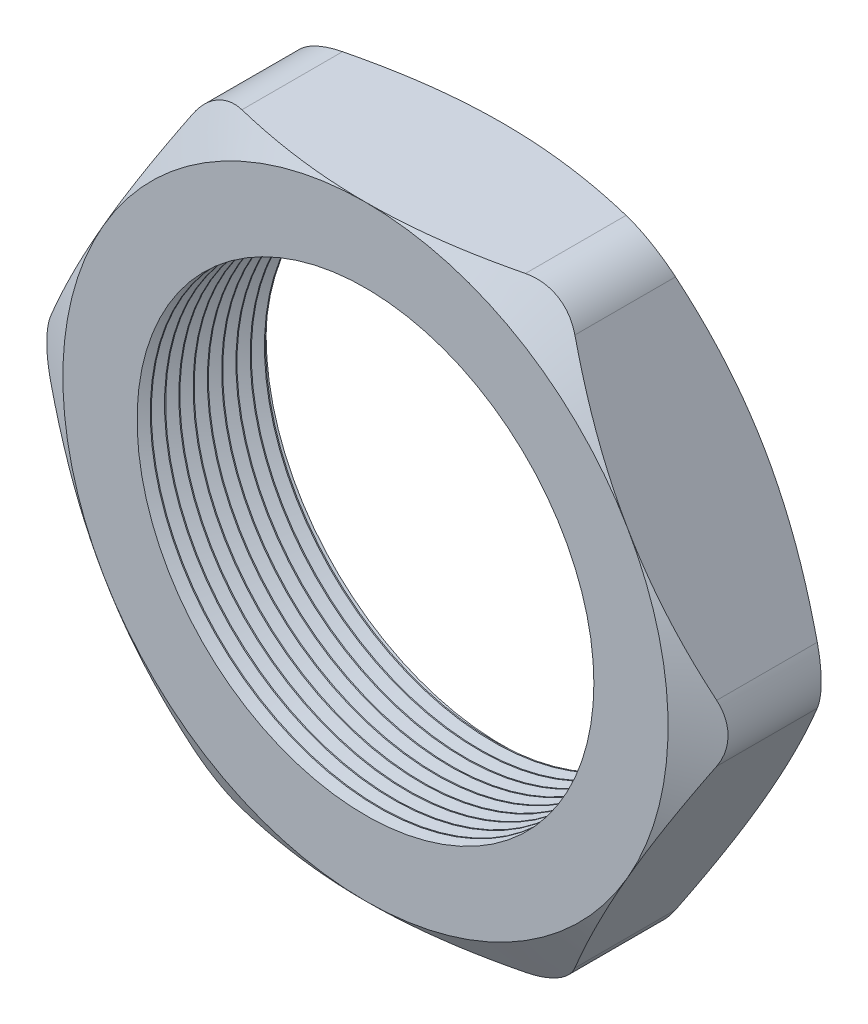
from build123d import *

# Parameters (mm, degrees)
SKETCH1_R          = 10.16
EXTRUDE1_DEPTH     = 6.096
SKETCH2_OUTSIDE_W  = 65.986
SKETCH2_OUTSIDE_H  = 61.82
SKETCH2_OUTSIDE_R  = 13.462
CUT_EXTRUDE1_DEPTH = 7.096
CUT_EXTRUDE1_DRAFT = -60
SKETCH3_OUTSIDE_W  = 65.986
SKETCH3_OUTSIDE_H  = 61.82
SKETCH3_OUTSIDE_R  = 13.462
CUT_EXTRUDE2_DEPTH = 7.096
CUT_EXTRUDE2_DRAFT = -60
FILLET1_R          = 2.54
LPATTERN1_COUNT    = 10
LPATTERN1_PITCH    = 0.635


with BuildPart() as part:
    # Sketch1 → Extrude1 (new body)
    with BuildSketch(Plane.XY):
        Polygon((-15.544578648, 0), (-7.772289324, -13.462), (7.772289324, -13.462), (15.544578648, 0), (7.772289324, 13.462), (-7.772289324, 13.462), align=None)
        Circle(SKETCH1_R, mode=Mode.SUBTRACT)
    extrude(amount=EXTRUDE1_DEPTH)


with BuildPart() as cut_extrude1_tool:
    # Sketch2 outside → Cut-Extrude1 (with draft: the straight prism first)
    with BuildSketch(Plane.XY.offset(6.096)):
        Rectangle(SKETCH2_OUTSIDE_W, SKETCH2_OUTSIDE_H)
        Circle(SKETCH2_OUTSIDE_R, mode=Mode.SUBTRACT)
    extrude(amount=-CUT_EXTRUDE1_DEPTH)
    # Cut-Extrude1: the draft: its side faces are tilted about the plane it starts from
    cut_extrude1_sides = [cut_extrude1_tool.faces().sort_by_distance(p)[0] for p in [
        (0, -30.91, 2.548),
        (32.993, 0, 2.548),
        (0, 30.91, 2.548),
        (-32.993, 0, 2.548),
        (-13.462, 0, 2.548),
    ]]
    draft(cut_extrude1_sides, Plane.XY.offset(6.096), CUT_EXTRUDE1_DRAFT)


with BuildPart() as part_1:
    add(part.part)

    # Cut-Extrude1: cut by cut_extrude1_tool
    add(cut_extrude1_tool.part, mode=Mode.SUBTRACT)


with BuildPart() as cut_extrude2_tool:
    # Sketch3 outside → Cut-Extrude2 (with draft: the straight prism first)
    with BuildSketch(Plane(origin=(0, 0, 0), x_dir=(-1, 0, 0), z_dir=(0, 0, -1))):
        Rectangle(SKETCH3_OUTSIDE_W, SKETCH3_OUTSIDE_H)
        Circle(SKETCH3_OUTSIDE_R, mode=Mode.SUBTRACT)
    extrude(amount=-CUT_EXTRUDE2_DEPTH)
    # Cut-Extrude2: the draft: its side faces are tilted about the plane it starts from
    cut_extrude2_sides = [cut_extrude2_tool.faces().sort_by_distance(p)[0] for p in [
        (0, -30.91, 3.548),
        (-32.993, 0, 3.548),
        (0, 30.91, 3.548),
        (32.993, 0, 3.548),
        (13.462, 0, 3.548),
    ]]
    draft(cut_extrude2_sides, Plane(origin=(0, 0, 0), x_dir=(-1, 0, 0), z_dir=(0, 0, -1)), CUT_EXTRUDE2_DRAFT)


with BuildPart() as part_2:
    add(part_1.part)

    # Cut-Extrude2: cut by cut_extrude2_tool
    add(cut_extrude2_tool.part, mode=Mode.SUBTRACT)

    # Fillet1
    fillet1_edges = [part_2.edges().sort_by_distance(p)[0] for p in [
        (15.544578648, 0, 3.048),
        (7.772289324, -13.462, 3.048),
        (-7.772289324, -13.462, 3.048),
        (-15.544578648, 0, 3.048),
        (-7.772289324, 13.462, 3.048),
        (7.772289324, 13.462, 3.048),
    ]]
    fillet(fillet1_edges, radius=FILLET1_R)

    # Sketch4 → Cut-Revolve1 (revolve, cut)
    with BuildSketch(Plane(origin=(0, 0, 0), x_dir=(1, 0, 0), z_dir=(0, 1, 0)), mode=Mode.PRIVATE) as cut_revolve1_sk:
        Polygon((-10.16, -6.096), (-10.16, -5.509412127), (-10.668, -5.802706063), align=None)
    cut_revolve1 = revolve(cut_revolve1_sk.sketch.rotate(Axis((0, 0, 0), (0, 0, 1)), 180), axis=Axis((0, 0, 0), (0, 0, 1)), mode=Mode.SUBTRACT)  # turned: the seam where the file's is

    # LPattern1: Cut-Revolve1 ×10
    with Locations(*[(0, 0, -i * LPATTERN1_PITCH) for i in range(1, LPATTERN1_COUNT)]):
        add(cut_revolve1, mode=Mode.SUBTRACT)


solid = part_2.part
